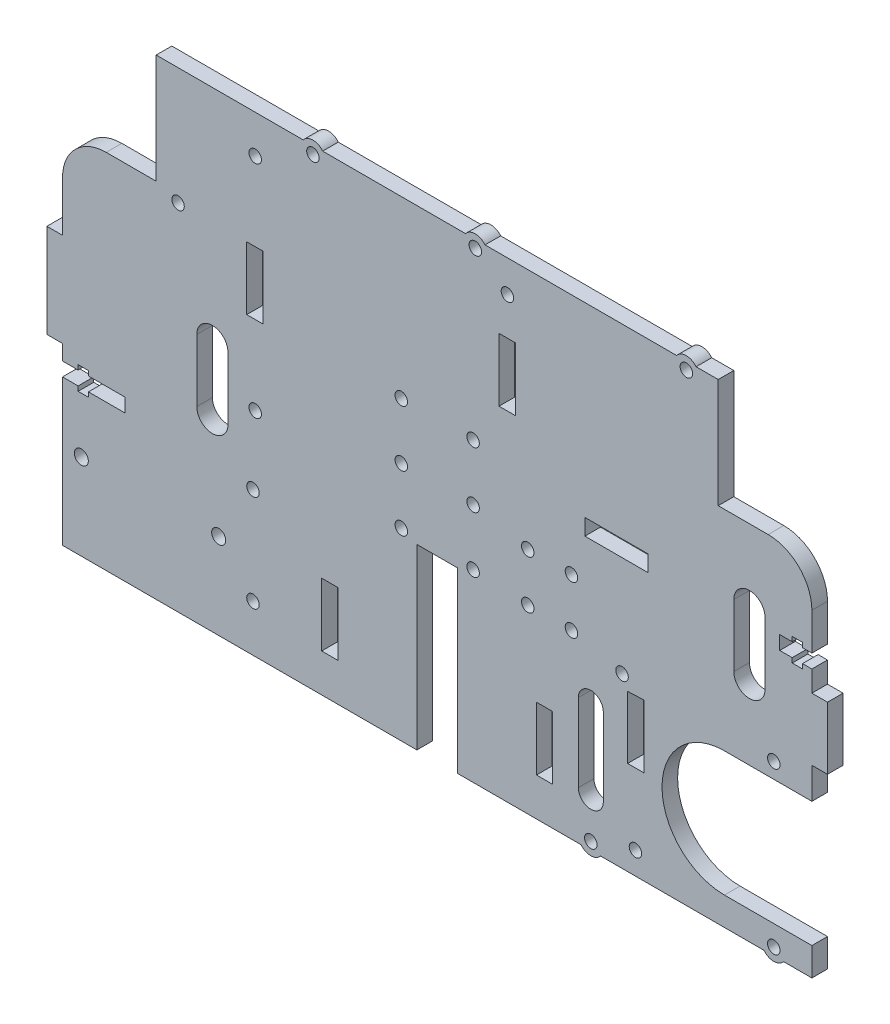
from build123d import *

# Parameters (mm, degrees)
SKETCH1_W           = 240
SKETCH1_H           = 151
BOSS_EXTRUDE1_DEPTH = 5
SKETCH3_W           = 13
SKETCH3_H           = 57
CUT_EXTRUDE2_DEPTH  = 10
SKETCH5_W           = 5.2
SKETCH5_H           = 20.2
CUT_EXTRUDE4_DEPTH  = 10
SKETCH6_R           = 2
CUT_EXTRUDE5_DEPTH  = 10
SKETCH7_R           = 2
CUT_EXTRUDE6_DEPTH  = 10
CUT_EXTRUDE7_DEPTH  = 10
SKETCH9_R           = 2
CUT_EXTRUDE8_DEPTH  = 10
SKETCH10_R          = 4
SKETCH10_R_2        = 2
BOSS_EXTRUDE2_DEPTH = 5
CUT_EXTRUDE10_DEPTH = 10
SKETCH13_W          = 30
SKETCH13_H          = 35
CUT_EXTRUDE11_DEPTH = 10
SKETCH16_R          = 2
CUT_EXTRUDE13_DEPTH = 5
CUT_EXTRUDE14_DEPTH = 5
CUT_EXTRUDE15_DEPTH = 5
SKETCH20_W          = 5.2
SKETCH20_H          = 20.2
CUT_EXTRUDE17_DEPTH = 10
SKETCH21_R          = 2
CUT_EXTRUDE18_DEPTH = 10
CUT_EXTRUDE20_DEPTH = 5
SKETCH25_R          = 2
CUT_EXTRUDE21_DEPTH = 5
SKETCH26_R          = 2
CUT_EXTRUDE22_DEPTH = 10
SKETCH27_R          = 4
SKETCH27_R_2        = 2
BOSS_EXTRUDE4_DEPTH = 5
FILLET1_R           = 14
SKETCH28_W          = 5.2
SKETCH28_H          = 20.2
CUT_EXTRUDE23_DEPTH = 5
SKETCH29_W          = 20.2
SKETCH29_H          = 5.2
CUT_EXTRUDE24_DEPTH = 5
SKETCH30_R          = 2
CUT_EXTRUDE25_DEPTH = 5
SKETCH31_R          = 4
SKETCH31_R_2        = 2
BOSS_EXTRUDE5_DEPTH = 5
SKETCH32_R          = 2
CUT_EXTRUDE26_DEPTH = 5
SKETCH33_W          = 5
SKETCH33_H          = 30
SKETCH33_H_2        = 20
BOSS_EXTRUDE6_DEPTH = 5
SKETCH34_R          = 2.25
CUT_EXTRUDE27_DEPTH = 5
CUT_EXTRUDE28_DEPTH = 5
SKETCH36_R          = 2
CUT_EXTRUDE29_DEPTH = 5


with BuildPart() as part:
    # Sketch1 → Boss-Extrude1 (new body)
    with BuildSketch(Plane.XY):
        Rectangle(SKETCH1_W, SKETCH1_H)
    extrude(amount=BOSS_EXTRUDE1_DEPTH)

    # Sketch3 → Cut-Extrude2 (cut)
    with BuildSketch(Plane(origin=(0, 0, 0), x_dir=(-1, 0, 0), z_dir=(0, 0, -1))):
        with Locations((0, -47)):
            Rectangle(SKETCH3_W, SKETCH3_H)
    extrude(amount=-CUT_EXTRUDE2_DEPTH, mode=Mode.SUBTRACT)

    # Sketch5 → Cut-Extrude4 (cut)
    with BuildSketch(Plane(origin=(0, 0, 0), x_dir=(-1, 0, 0), z_dir=(0, 0, -1))):
        with Locations((-34.4, -53.2)):
            Rectangle(SKETCH5_W, SKETCH5_H)
        with Locations((34.4, -53.2)):
            Rectangle(SKETCH5_W, SKETCH5_H)
    extrude(amount=-CUT_EXTRUDE4_DEPTH, mode=Mode.SUBTRACT)

    # Sketch6 → Cut-Extrude5 (cut)
    with BuildSketch(Plane(origin=(0, 0, 0), x_dir=(-1, 0, 0), z_dir=(0, 0, -1))):
        with Locations((11.5, 19.5)):
            Circle(SKETCH6_R)
        with Locations((11.5, 1.5)):
            Circle(SKETCH6_R)
        with Locations((11.5, -16.5)):
            Circle(SKETCH6_R)
        with Locations((-11.5, -16.5)):
            Circle(SKETCH6_R)
        with Locations((-11.5, 1.5)):
            Circle(SKETCH6_R)
        with Locations((-11.5, 19.5)):
            Circle(SKETCH6_R)
    extrude(amount=-CUT_EXTRUDE5_DEPTH, mode=Mode.SUBTRACT)

    # Sketch7 → Cut-Extrude6 (cut)
    with BuildSketch(Plane(origin=(0, 0, 0), x_dir=(-1, 0, 0), z_dir=(0, 0, -1))):
        with Locations((-43, -2.1)):
            Circle(SKETCH7_R)
        with Locations((-43, -17.6)):
            Circle(SKETCH7_R)
        with Locations((-29, -17.6)):
            Circle(SKETCH7_R)
        with Locations((-29, -2.1)):
            Circle(SKETCH7_R)
    extrude(amount=-CUT_EXTRUDE6_DEPTH, mode=Mode.SUBTRACT)

    # Sketch8 → Cut-Extrude7 (cut)
    with BuildSketch(Plane(origin=(0, 0, 0), x_dir=(-1, 0, 0), z_dir=(0, 0, -1))):
        with BuildLine():
            Line((-120, -26.5), (-92, -26.5))
            ThreePointArc((-92, -26.5), (-72, -46.5), (-92, -66.5))
            Line((-92, -66.5), (-120, -66.5))
            Line((-120, -66.5), (-120, -26.5))
        make_face()
    extrude(amount=-CUT_EXTRUDE7_DEPTH, mode=Mode.SUBTRACT)

    # Sketch9 → Cut-Extrude8 (cut)
    with BuildSketch(Plane(origin=(0, 0, 0), x_dir=(-1, 0, 0), z_dir=(0, 0, -1))):
        with Locations((-59.2, -21.5)):
            Circle(SKETCH9_R)
        with Locations((-107.8, -21.5)):
            Circle(SKETCH9_R)
        with Locations((-49.2, -73)):
            Circle(SKETCH9_R)
        with Locations((-107.8, -73)):
            Circle(SKETCH9_R)
    extrude(amount=-CUT_EXTRUDE8_DEPTH, mode=Mode.SUBTRACT)

    # Sketch10 → Boss-Extrude2 (add)
    with BuildSketch(Plane(origin=(0, 0, 0), x_dir=(-1, 0, 0), z_dir=(0, 0, -1))):
        with Locations((-107.8, -73)):
            Circle(SKETCH10_R)
        with Locations((-107.8, -73)):
            Circle(SKETCH10_R_2, mode=Mode.SUBTRACT)
        with Locations((-49.2, -73)):
            Circle(SKETCH10_R)
        with Locations((-49.2, -73)):
            Circle(SKETCH10_R_2, mode=Mode.SUBTRACT)
    extrude(amount=-BOSS_EXTRUDE2_DEPTH)

    # Sketch12 → Cut-Extrude10 (cut)
    with BuildSketch(Plane(origin=(0, 0, 0), x_dir=(-1, 0, 0), z_dir=(0, 0, -1))):
        with BuildLine():
            Line((-45.2, -35.107061825), (-45.2, -60.107061825))
            ThreePointArc((-45.2, -60.107061825), (-49.2, -64.107061825), (-53.2, -60.107061825))
            Line((-53.2, -60.107061825), (-53.2, -35.107061825))
            ThreePointArc((-53.2, -35.107061825), (-49.2, -31.107061825), (-45.2, -35.107061825))
        make_face()
    extrude(amount=-CUT_EXTRUDE10_DEPTH, mode=Mode.SUBTRACT)

    # Sketch13 → Cut-Extrude11 (cut)
    with BuildSketch(Plane(origin=(0, 0, 0), x_dir=(-1, 0, 0), z_dir=(0, 0, -1))):
        with Locations((-105, 58)):
            Rectangle(SKETCH13_W, SKETCH13_H)
        with Locations((105, 58)):
            Rectangle(SKETCH13_W, SKETCH13_H)
    extrude(amount=-CUT_EXTRUDE11_DEPTH, mode=Mode.SUBTRACT)

    # Sketch16 → Cut-Extrude13 (cut)
    with BuildSketch(Plane(origin=(0, 0, 0), x_dir=(-1, 0, 0), z_dir=(0, 0, -1))):
        with Locations((59, -29.5)):
            Circle(SKETCH16_R)
        with Locations((59, -60.5)):
            Circle(SKETCH16_R)
    extrude(amount=-CUT_EXTRUDE13_DEPTH, mode=Mode.SUBTRACT)

    # Sketch17 → Cut-Extrude14 (cut)
    with BuildSketch(Plane(origin=(0, 0, 0), x_dir=(-1, 0, 0), z_dir=(0, 0, -1))):
        with BuildLine():
            Line((-95, 17), (-95, -3))
            ThreePointArc((-95, -3), (-100, -8), (-105, -3))
            Line((-105, -3), (-105, 17))
            ThreePointArc((-105, 17), (-100, 22), (-95, 17))
        make_face()
    extrude(amount=-CUT_EXTRUDE14_DEPTH, mode=Mode.SUBTRACT)

    # Sketch18 → Cut-Extrude15 (cut)
    with BuildSketch(Plane(origin=(0, 0, 0), x_dir=(-1, 0, 0), z_dir=(0, 0, -1))):
        with BuildLine():
            Line((67, -15.5), (67, 4.5))
            ThreePointArc((67, 4.5), (72, 9.5), (77, 4.5))
            Line((77, 4.5), (77, -15.5))
            ThreePointArc((77, -15.5), (72, -20.5), (67, -15.5))
        make_face()
    extrude(amount=-CUT_EXTRUDE15_DEPTH, mode=Mode.SUBTRACT)

    # Sketch20 → Cut-Extrude17 (cut)
    with BuildSketch(Plane(origin=(0, 0, 0), x_dir=(-1, 0, 0), z_dir=(0, 0, -1))):
        with Locations((58.395562695, 28.1)):
            Rectangle(SKETCH20_W, SKETCH20_H)
    extrude(amount=-CUT_EXTRUDE17_DEPTH, mode=Mode.SUBTRACT)

    # Sketch21 → Cut-Extrude18 (cut)
    with BuildSketch(Plane(origin=(0, 0, 0), x_dir=(-1, 0, 0), z_dir=(0, 0, -1))):
        with Locations((58.295562695, -7.3)):
            Circle(SKETCH21_R)
        with Locations((58.295562695, 63.3)):
            Circle(SKETCH21_R)
    extrude(amount=-CUT_EXTRUDE18_DEPTH, mode=Mode.SUBTRACT)

    # Sketch24 → Cut-Extrude20 (cut)
    with BuildSketch(Plane.XY.offset(5)):
        Polygon((66.2, -45.5), (66.196152437, -25.300000366), (61, -25.5), (61, -45.5), align=None)
    extrude(amount=-CUT_EXTRUDE20_DEPTH, mode=Mode.SUBTRACT)

    # Sketch25 → Cut-Extrude21 (cut)
    with BuildSketch(Plane(origin=(0, 0, 0), x_dir=(-1, 0, 0), z_dir=(0, 0, -1))):
        with Locations((-63.5, -68.3)):
            Circle(SKETCH25_R)
    extrude(amount=-CUT_EXTRUDE21_DEPTH, mode=Mode.SUBTRACT)

    # Sketch26 → Cut-Extrude22 (cut)
    with BuildSketch(Plane(origin=(0, 0, 0), x_dir=(-1, 0, 0), z_dir=(0, 0, -1))):
        with Locations((39.8, 73)):
            Circle(SKETCH26_R)
        with Locations((-12.2, 73)):
            Circle(SKETCH26_R)
    extrude(amount=-CUT_EXTRUDE22_DEPTH, mode=Mode.SUBTRACT)

    # Sketch27 → Boss-Extrude4 (add)
    with BuildSketch(Plane(origin=(0, 0, 0), x_dir=(-1, 0, 0), z_dir=(0, 0, -1))):
        with Locations((39.8, 73)):
            Circle(SKETCH27_R)
        with Locations((39.8, 73)):
            Circle(SKETCH27_R_2, mode=Mode.SUBTRACT)
        with Locations((-12.2, 73)):
            Circle(SKETCH27_R)
        with Locations((-12.2, 73)):
            Circle(SKETCH27_R_2, mode=Mode.SUBTRACT)
    extrude(amount=-BOSS_EXTRUDE4_DEPTH)

    # Fillet1
    fillet1_edges = [part.edges().sort_by_distance(p)[0] for p in [
        (120, 40.5, 2.5),
        (-120, 40.5, 2.5),
    ]]
    fillet(fillet1_edges, radius=FILLET1_R)

    # Sketch28 → Cut-Extrude23 (cut)
    with BuildSketch(Plane.XY.offset(5)):
        with Locations((22.4, 43.1)):
            Rectangle(SKETCH28_W, SKETCH28_H)
    extrude(amount=-CUT_EXTRUDE23_DEPTH, mode=Mode.SUBTRACT)

    # Sketch29 → Cut-Extrude24 (cut)
    with BuildSketch(Plane.XY.offset(5)):
        with Locations((57.4, 13.3)):
            Rectangle(SKETCH29_W, SKETCH29_H)
    extrude(amount=-CUT_EXTRUDE24_DEPTH, mode=Mode.SUBTRACT)

    # Sketch30 → Cut-Extrude25 (cut)
    with BuildSketch(Plane(origin=(0, 0, 0), x_dir=(-1, 0, 0), z_dir=(0, 0, -1))):
        with Locations((-79.8, 73)):
            Circle(SKETCH30_R)
    extrude(amount=-CUT_EXTRUDE25_DEPTH, mode=Mode.SUBTRACT)

    # Sketch31 → Boss-Extrude5 (add)
    with BuildSketch(Plane(origin=(0, 0, 0), x_dir=(-1, 0, 0), z_dir=(0, 0, -1))):
        with Locations((-79.8, 73)):
            Circle(SKETCH31_R)
        with Locations((-79.8, 73)):
            Circle(SKETCH31_R_2, mode=Mode.SUBTRACT)
    extrude(amount=-BOSS_EXTRUDE5_DEPTH)

    # Sketch32 → Cut-Extrude26 (cut)
    with BuildSketch(Plane(origin=(0, 0, 0), x_dir=(-1, 0, 0), z_dir=(0, 0, -1))):
        with Locations((82.999989356, 38)):
            Circle(SKETCH32_R)
    extrude(amount=-CUT_EXTRUDE26_DEPTH, mode=Mode.SUBTRACT)

    # Sketch33 → Boss-Extrude6 (add)
    with BuildSketch(Plane(origin=(0, 0, 0), x_dir=(-1, 0, 0), z_dir=(0, 0, -1))):
        with Locations((122.5, -4.5)):
            Rectangle(SKETCH33_W, SKETCH33_H)
        with Locations((-122.5, -6.5)):
            Rectangle(SKETCH33_W, SKETCH33_H_2)
    extrude(amount=-BOSS_EXTRUDE6_DEPTH)

    # Sketch34 → Cut-Extrude27 (cut)
    with BuildSketch(Plane(origin=(0, 0, 0), x_dir=(-1, 0, 0), z_dir=(0, 0, -1))):
        with Locations((113.98, -48)):
            Circle(SKETCH34_R)
        with Locations((69.98, -48)):
            Circle(SKETCH34_R)
    extrude(amount=-CUT_EXTRUDE27_DEPTH, mode=Mode.SUBTRACT)

    # Sketch35 → Cut-Extrude28 (cut)
    with BuildSketch(Plane(origin=(0, 0, 0), x_dir=(-1, 0, 0), z_dir=(0, 0, -1))):
        Polygon((-120, 14.605611853), (-117, 14.605611853), (-117, 16.105611853), (-113.7, 16.105611853), (-113.7, 14.605611853), (-109.705118332, 14.605611853), (-109.705118332, 10.205611853), (-113.7, 10.205611853), (-113.7, 8.705611853), (-117, 8.705611853), (-117, 10.205611853), (-120, 10.205611853), align=None)
        Polygon((100, -24.37851787), (111.7, -24.37851787), (111.7, -22.87851787), (115, -22.87851787), (115, -24.37851787), (120, -24.37851787), (120, -28.77851787), (115, -28.77851787), (115, -30.27851787), (111.7, -30.27851787), (111.7, -28.77851787), (100, -28.77851787), align=None)
    extrude(amount=-CUT_EXTRUDE28_DEPTH, mode=Mode.SUBTRACT)

    # Sketch36 → Cut-Extrude29 (cut)
    with BuildSketch(Plane(origin=(0, 0, 0), x_dir=(-1, 0, 0), z_dir=(0, 0, -1))):
        with Locations((-22.5, 65.3)):
            Circle(SKETCH36_R)
    extrude(amount=-CUT_EXTRUDE29_DEPTH, mode=Mode.SUBTRACT)


solid = part.part
